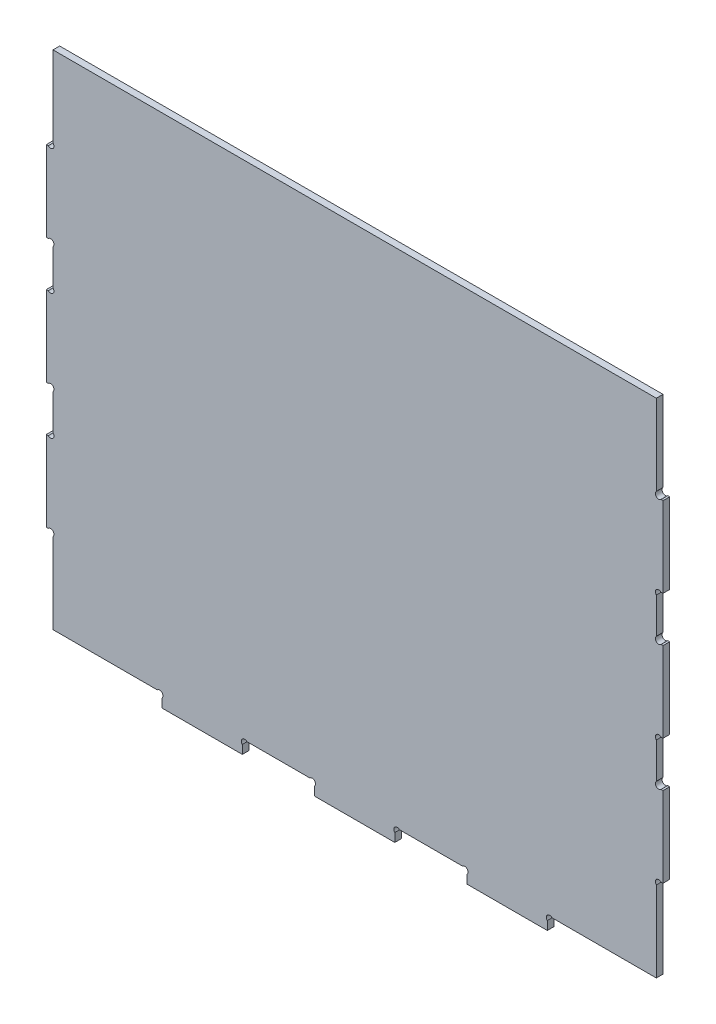
from build123d import *

# Parameters (mm, degrees)
SKETCH2_W               = 286.300000032
SKETCH2_H               = 238.275
BOSS_EXTRUDE1_DEPTH     = 1.5875
SKETCH4_W               = 3.175
SKETCH4_H               = 38.1
SKETCH4_W_2             = 38.1
SKETCH4_H_2             = 6.35
WELD_TABS_EXTRUDE_DEPTH = 3.175
SKETCH5_R               = 1.5875
CUT_EXTRUDE1_DEPTH      = 3.175


with BuildPart() as part:
    # Sketch2 → Boss-Extrude1 (new body, symmetric)
    with BuildSketch(Plane.XY):
        with Locations((-144.737500016, 122.3125)):
            Rectangle(SKETCH2_W, SKETCH2_H)
    extrude(amount=BOSS_EXTRUDE1_DEPTH, both=True)

    # Sketch4 → Weld Tabs Extrude (add)
    with BuildSketch(Plane(origin=(0, 0, -1.5875), x_dir=(-1, 0, 0), z_dir=(0, 0, -1))):
        with Locations((0, 181.88125)):
            Rectangle(SKETCH4_W, SKETCH4_H)
        with Locations((0, 122.3125)):
            Rectangle(SKETCH4_W, SKETCH4_H)
        with Locations((0, 62.74375)):
            Rectangle(SKETCH4_W, SKETCH4_H)
        with Locations((72.368750008, 0)):
            Rectangle(SKETCH4_W_2, SKETCH4_H_2)
        with Locations((144.737500016, 0)):
            Rectangle(SKETCH4_W_2, SKETCH4_H_2)
        with Locations((217.106250024, 0)):
            Rectangle(SKETCH4_W_2, SKETCH4_H_2)
        with Locations((289.475000032, 181.88125)):
            Rectangle(SKETCH4_W, SKETCH4_H)
        with Locations((289.475000032, 122.3125)):
            Rectangle(SKETCH4_W, SKETCH4_H)
        with Locations((289.475000032, 62.74375)):
            Rectangle(SKETCH4_W, SKETCH4_H)
    extrude(amount=-WELD_TABS_EXTRUDE_DEPTH)

    # Sketch5 → Cut-Extrude1 (cut)
    with BuildSketch(Plane.XY.offset(1.5875)):
        with Locations((-0.464967985, 202.053782015)):
            Circle(SKETCH5_R)
        with Locations((-0.464967985, 142.485032015)):
            Circle(SKETCH5_R)
        with Locations((-0.464967985, 82.916282015)):
            Circle(SKETCH5_R)
        with Locations((-0.464967985, 161.708717985)):
            Circle(SKETCH5_R)
        with Locations((-0.464967985, 102.139967985)):
            Circle(SKETCH5_R)
        with Locations((-0.464967985, 42.571217985)):
            Circle(SKETCH5_R)
        with Locations((-289.010032047, 42.571217985)):
            Circle(SKETCH5_R)
        with Locations((-289.010032047, 82.916282015)):
            Circle(SKETCH5_R)
        with Locations((-289.010032047, 102.139967985)):
            Circle(SKETCH5_R)
        with Locations((-289.010032047, 142.485032015)):
            Circle(SKETCH5_R)
        with Locations((-289.010032047, 161.708717985)):
            Circle(SKETCH5_R)
        with Locations((-289.010032047, 202.053782015)):
            Circle(SKETCH5_R)
        with Locations((-52.196217993, 2.052467985)):
            Circle(SKETCH5_R)
        with Locations((-92.541282023, 2.052467985)):
            Circle(SKETCH5_R)
        with Locations((-124.564968001, 2.052467985)):
            Circle(SKETCH5_R)
        with Locations((-237.278782039, 2.052467985)):
            Circle(SKETCH5_R)
        with Locations((-196.933718009, 2.052467985)):
            Circle(SKETCH5_R)
        with Locations((-164.910032031, 2.052467985)):
            Circle(SKETCH5_R)
    extrude(amount=-CUT_EXTRUDE1_DEPTH, mode=Mode.SUBTRACT)


solid = part.part
